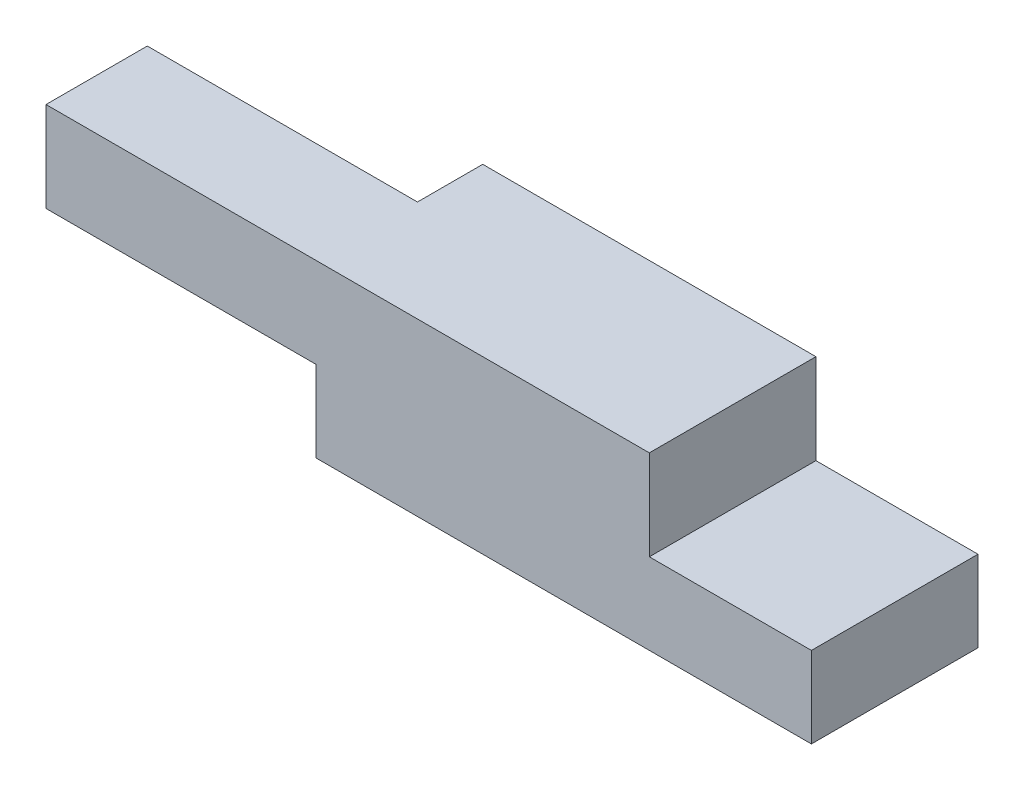
from build123d import *

# Parameters (mm, degrees)
SKETCH1_W           = 55
SKETCH1_H           = 18.5
BOSS_EXTRUDE1_DEPTH = 9
SKETCH2_W           = 37
SKETCH2_H           = 18.5
BOSS_EXTRUDE2_DEPTH = 10
SKETCH3_W           = 4
SKETCH3_H           = 19
BOSS_EXTRUDE3_DEPTH = 4
SKETCH4_W           = 11.25
SKETCH4_H           = 10
BOSS_EXTRUDE4_DEPTH = 30


with BuildPart() as part:
    # Sketch1 → Boss-Extrude1 (new body)
    with BuildSketch(Plane(origin=(0, 0, 0), x_dir=(1, 0, 0), z_dir=(0, 1, 0))):
        Rectangle(SKETCH1_W, SKETCH1_H)
    extrude(amount=BOSS_EXTRUDE1_DEPTH)

    # Sketch2 → Boss-Extrude2 (add)
    with BuildSketch(Plane(origin=(0, 9, 0), x_dir=(1, 0, 0), z_dir=(0, 1, 0))):
        with Locations((-9, 0)):
            Rectangle(SKETCH2_W, SKETCH2_H)
    extrude(amount=BOSS_EXTRUDE2_DEPTH)

    # Sketch3 → Boss-Extrude3 (add)
    with BuildSketch(Plane.ZY.offset(27.5)):
        with Locations((0, 9.5)):
            Rectangle(SKETCH3_W, SKETCH3_H)
    extrude(amount=BOSS_EXTRUDE3_DEPTH)

    # Sketch4 → Boss-Extrude4 (add)
    with BuildSketch(Plane.ZY.offset(27.5)):
        with Locations((3.625, 14)):
            Rectangle(SKETCH4_W, SKETCH4_H)
    extrude(amount=BOSS_EXTRUDE4_DEPTH)


solid = part.part
